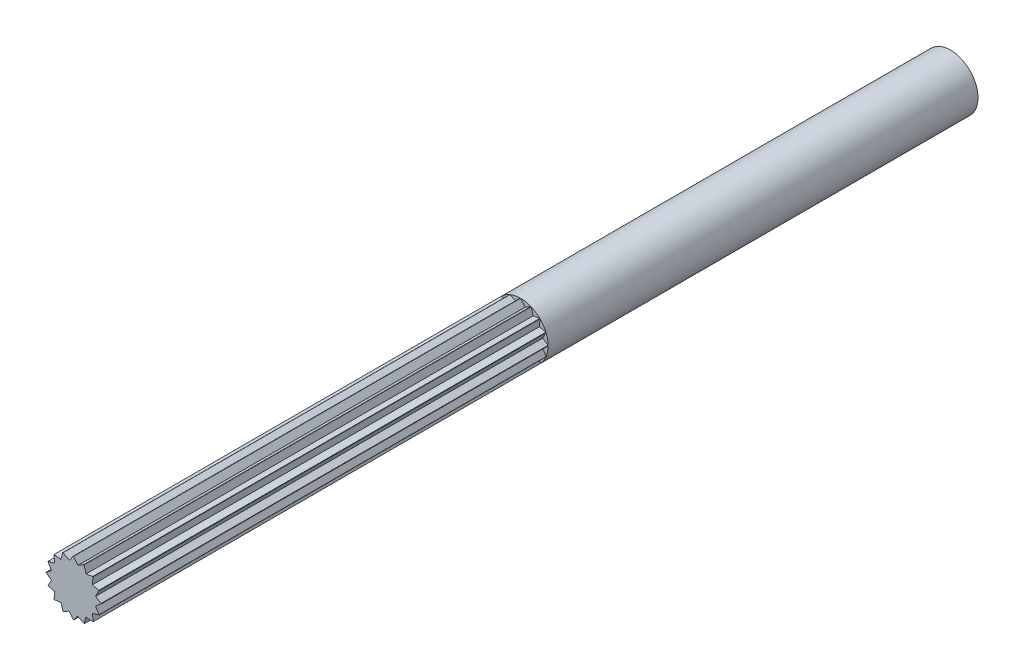
from build123d import *

# Parameters (mm, degrees)
SKETCH1_R      = 1.6
EXTRUDE1_DEPTH = 51
EXTRUDE8_DEPTH = 26


with BuildPart() as part:
    # Sketch1 → Extrude1 (new body)
    with BuildSketch(Plane.XY):
        Circle(SKETCH1_R)
    extrude(amount=EXTRUDE1_DEPTH)

    # Sketch2 → Extrude8 (cut)
    with BuildSketch(Plane.XY.offset(51)):
        Polygon((1.286441807, 0.233094665), (1.599727071, 0.029551611), (1.873059743, 0.450254242), (1.471735058, 0.609612621), align=None)
        Polygon((1.6, 0), (1.281363749, -0.259562299), (1.485250033, -0.595006167), (1.785955756, -0.399980732), align=None)
        Polygon((1.478207252, -0.612293492), (1.095008295, -0.714298592), (1.15002382, -1.112405148), (1.560600042, -1.055666403), align=None)
        Polygon((1.13137085, -1.13137085), (0.720697062, -1.090807678), (0.629158613, -1.471108235), (1.033870669, -1.568522539), align=None)
        Polygon((0.612293492, -1.478207252), (0.238710912, -1.285411508), (0.009348192, -1.599972691), (0.334676963, -1.792391164), align=None)
        Polygon((0, -1.6), (-0.254390706, -1.282400489), (-0.600470531, -1.483049271), (-0.412348506, -1.807522895), align=None)
        Polygon((-0.612293492, -1.478207252), (-0.720697062, -1.090807678), (-1.121623142, -1.141035288), (-1.075884592, -1.506128861), align=None)
        Polygon((-1.13137085, -1.13137085), (-1.086958525, -0.726489374), (-1.474329588, -0.621572413), (-1.568528471, -0.969370531), align=None)
        Polygon((-1.478207252, -0.612293492), (-1.285411508, -0.238710912), (-1.599972691, -0.009348192), (-1.864675344, -0.389243799), align=None)
        Polygon((-1.6, 0), (-1.285411508, 0.238710912), (-1.482902222, 0.600833588), (-1.904214705, 0.37106255), align=None)
        Polygon((-1.478207252, 0.612293492), (-1.099318185, 0.707647634), (-1.138761595, 1.123931506), (-1.503705091, 1.08935266), align=None)
        Polygon((-1.13137085, 1.13137085), (-0.732466712, 1.082939592), (-0.627095181, 1.471989006), (-1.152553281, 1.43226765), align=None)
        Polygon((-0.612293492, 1.478207252), (-0.238710912, 1.285411508), (-0.019596398, 1.59987999), (-0.507182841, 1.659078234), align=None)
        Polygon((0, 1.6), (0.261567483, 1.280955931), (0.598789697, 1.483728715), (0.43006534, 1.601292025), (0.238504204, 1.734767485), align=None)
        Polygon((0.612293492, 1.478207252), (0.732466712, 1.082939592), (1.117347771, 1.145222231), (1.056496245, 1.5212596), align=None)
        Polygon((1.13137085, 1.13137085), (1.095008295, 0.714298592), (1.471735058, 0.627690942), (1.549987973, 0.992566635), align=None)
    extrude(amount=-EXTRUDE8_DEPTH, mode=Mode.SUBTRACT)


solid = part.part
